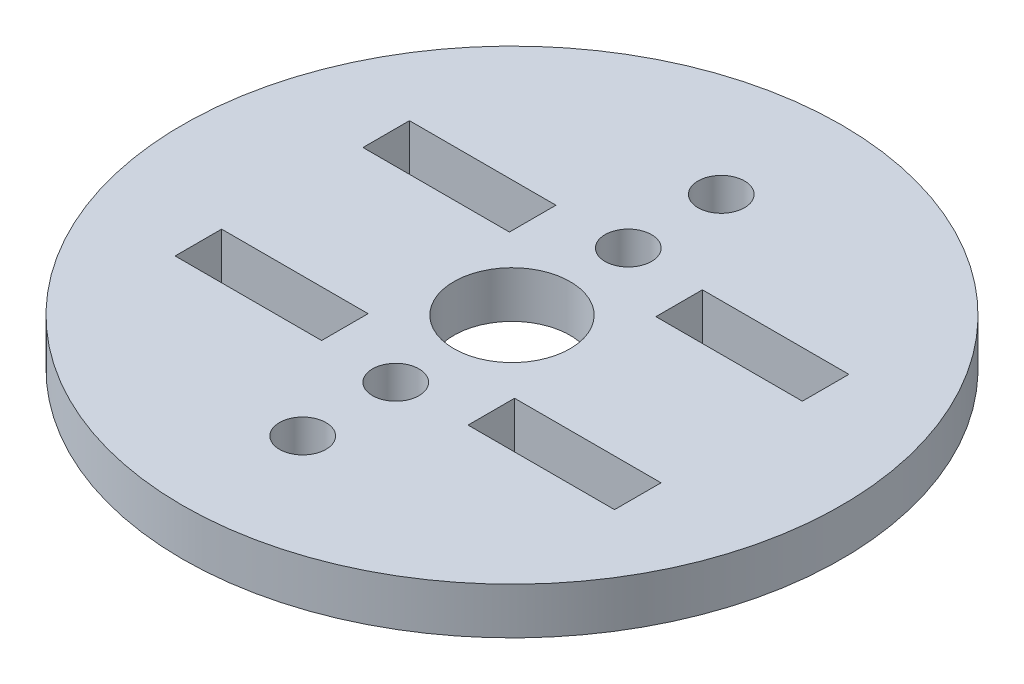
from build123d import *

# Parameters (mm, degrees)
CROQUIS1_R              = 22.5
CROQUIS1_R_2            = 3.96875
CROQUIS1_R_3            = 1.5875
CROQUIS1_W              = 10
CROQUIS1_H              = 3.175
SALIENTE_EXTRUIR1_DEPTH = 3.175


with BuildPart() as part:
    # Croquis1 → Saliente-Extruir1 (new body)
    with BuildSketch(Plane(origin=(0, 0, 0), x_dir=(1, 0, 0), z_dir=(0, 1, 0))):
        Circle(CROQUIS1_R)
        Circle(CROQUIS1_R_2, mode=Mode.SUBTRACT)
        with Locations((0, 7.9375)):
            Circle(CROQUIS1_R_3, mode=Mode.SUBTRACT)
        with Locations((0, -7.9375)):
            Circle(CROQUIS1_R_3, mode=Mode.SUBTRACT)
        with Locations((0, 14.2875)):
            Circle(CROQUIS1_R_3, mode=Mode.SUBTRACT)
        with Locations((0, -14.2875)):
            Circle(CROQUIS1_R_3, mode=Mode.SUBTRACT)
        with Locations((-10, 6.4125)):
            Rectangle(CROQUIS1_W, CROQUIS1_H, mode=Mode.SUBTRACT)
        with Locations((10, 6.4125)):
            Rectangle(CROQUIS1_W, CROQUIS1_H, mode=Mode.SUBTRACT)
        with Locations((-10, -6.4125)):
            Rectangle(CROQUIS1_W, CROQUIS1_H, mode=Mode.SUBTRACT)
        with Locations((10, -6.4125)):
            Rectangle(CROQUIS1_W, CROQUIS1_H, mode=Mode.SUBTRACT)
    extrude(amount=SALIENTE_EXTRUIR1_DEPTH)


solid = part.part
